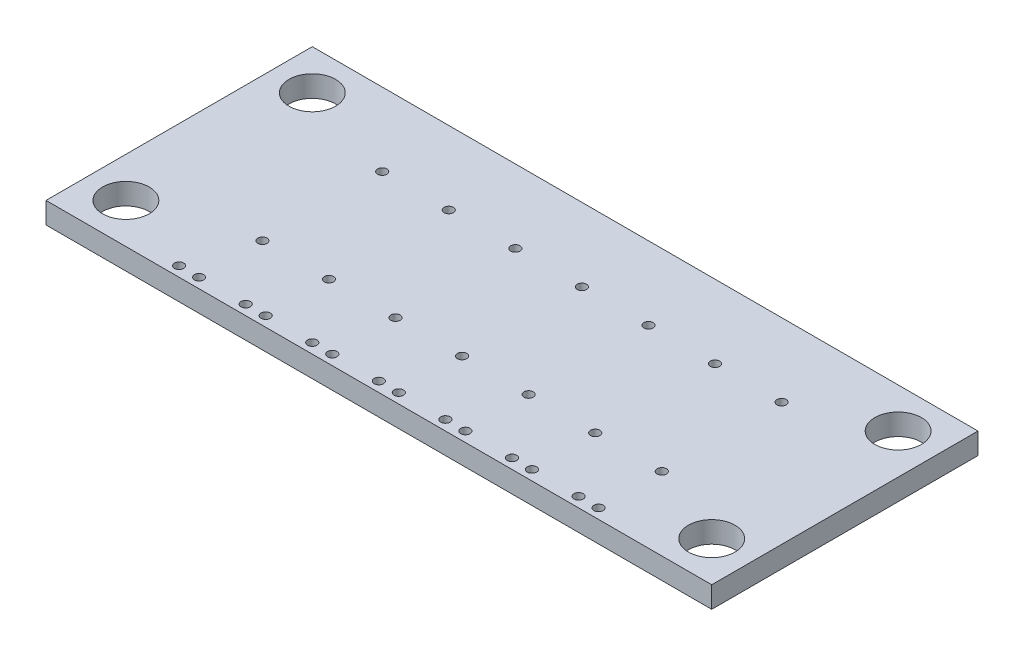
from build123d import *

# Parameters (mm, degrees)
SKETCH1_W           = 50
SKETCH1_H           = 20
SKETCH1_R           = 1.75
BOSS_EXTRUDE1_DEPTH = 1.6
SKETCH3_R           = 0.35
CUT_EXTRUDE1_DEPTH  = 2.6


with BuildPart() as part:
    # Sketch1 → Boss-Extrude1 (new body)
    with BuildSketch(Plane(origin=(0, 0, 0), x_dir=(1, 0, 0), z_dir=(0, 1, 0))):
        with Locations((25, 10)):
            Rectangle(SKETCH1_W, SKETCH1_H)
        with Locations((3, 17)):
            Circle(SKETCH1_R, mode=Mode.SUBTRACT)
        with Locations((47, 3)):
            Circle(SKETCH1_R, mode=Mode.SUBTRACT)
        with Locations((3, 3)):
            Circle(SKETCH1_R, mode=Mode.SUBTRACT)
        with Locations((47, 17)):
            Circle(SKETCH1_R, mode=Mode.SUBTRACT)
    extrude(amount=BOSS_EXTRUDE1_DEPTH)

    # Sketch3 → Cut-Extrude1 (cut, through all)
    with BuildSketch(Plane(origin=(0, 1.6, 0), x_dir=(1, 0, 0), z_dir=(0, 1, 0))):
        with Locations((9.25, 0.75)):
            Circle(SKETCH3_R)
        with Locations((10.75, 0.75)):
            Circle(SKETCH3_R)
        with Locations((10.75, 5.5)):
            Circle(SKETCH3_R)
        with Locations((10.75, 14.5)):
            Circle(SKETCH3_R)
        with Locations((15.75, 5.5)):
            Circle(SKETCH3_R)
        with Locations((15.75, 14.5)):
            Circle(SKETCH3_R)
        with Locations((15.75, 0.75)):
            Circle(SKETCH3_R)
        with Locations((14.25, 0.75)):
            Circle(SKETCH3_R)
        with Locations((20.75, 5.5)):
            Circle(SKETCH3_R)
        with Locations((20.75, 14.5)):
            Circle(SKETCH3_R)
        with Locations((20.75, 0.75)):
            Circle(SKETCH3_R)
        with Locations((19.25, 0.75)):
            Circle(SKETCH3_R)
        with Locations((25.75, 5.5)):
            Circle(SKETCH3_R)
        with Locations((25.75, 14.5)):
            Circle(SKETCH3_R)
        with Locations((25.75, 0.75)):
            Circle(SKETCH3_R)
        with Locations((24.25, 0.75)):
            Circle(SKETCH3_R)
        with Locations((30.75, 5.5)):
            Circle(SKETCH3_R)
        with Locations((30.75, 14.5)):
            Circle(SKETCH3_R)
        with Locations((30.75, 0.75)):
            Circle(SKETCH3_R)
        with Locations((29.25, 0.75)):
            Circle(SKETCH3_R)
        with Locations((35.75, 5.5)):
            Circle(SKETCH3_R)
        with Locations((35.75, 14.5)):
            Circle(SKETCH3_R)
        with Locations((35.75, 0.75)):
            Circle(SKETCH3_R)
        with Locations((34.25, 0.75)):
            Circle(SKETCH3_R)
        with Locations((40.75, 5.5)):
            Circle(SKETCH3_R)
        with Locations((40.75, 14.5)):
            Circle(SKETCH3_R)
        with Locations((40.75, 0.75)):
            Circle(SKETCH3_R)
        with Locations((39.25, 0.75)):
            Circle(SKETCH3_R)
    extrude(amount=-CUT_EXTRUDE1_DEPTH, mode=Mode.SUBTRACT)


solid = part.part
